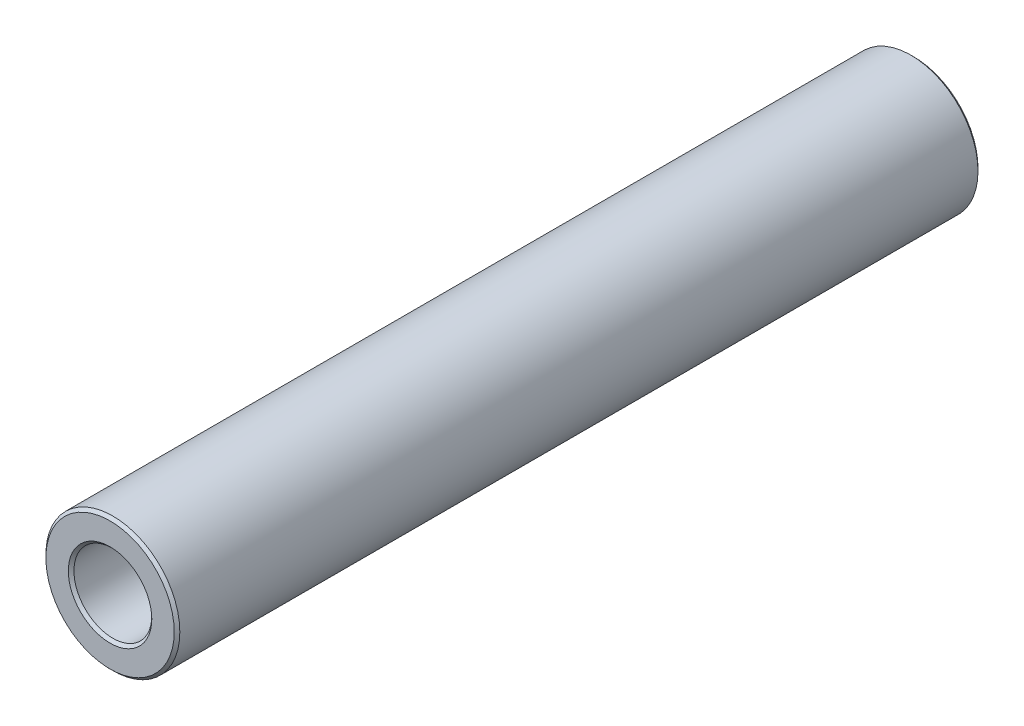
from build123d import *

# Parameters (mm, degrees)
BOSS_EXTRUDE1_DEPTH      = 28.575
BOSS_EXTRUDE1_DEPTH_BACK = 28.575
SKETCH3_R                = 4.7625
SKETCH3_R_2              = 2.7686
CHAMFER1_SIZE            = 0.19939


with BuildPart() as part:
    # Sketch3 → Boss-Extrude1 (new, two sides: drawn at the far end of the back side and taken through both)
    with BuildSketch(Plane.XY.offset(-BOSS_EXTRUDE1_DEPTH_BACK)):
        Circle(SKETCH3_R)
        Circle(SKETCH3_R_2, mode=Mode.SUBTRACT)
    extrude(amount=BOSS_EXTRUDE1_DEPTH + BOSS_EXTRUDE1_DEPTH_BACK)

    # Chamfer1
    chamfer1_edges = [part.edges().sort_by_distance(p)[0] for p in [
        (-4.7625, 0, -28.575),
        (-2.7686, 0, -28.575),
        (-4.7625, 0, 28.575),
        (-2.7686, 0, 28.575),
    ]]
    chamfer(chamfer1_edges, length=CHAMFER1_SIZE)


solid = part.part
